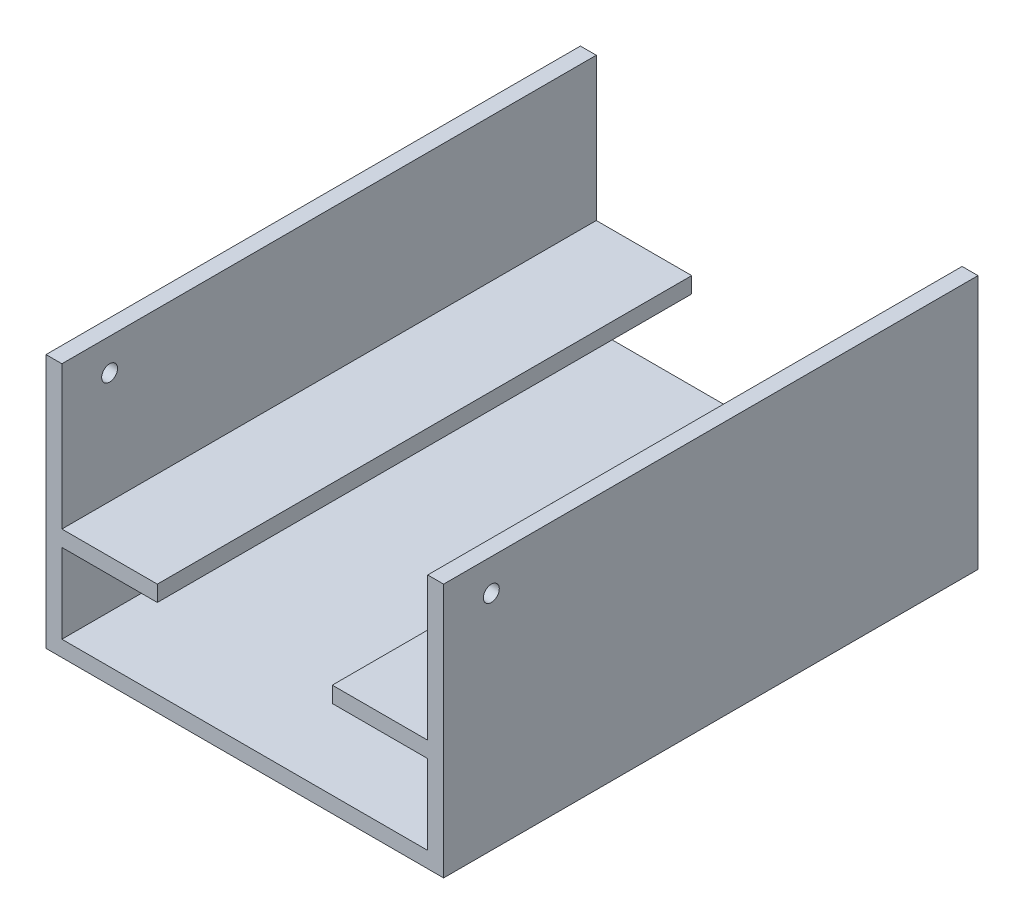
from build123d import *

# Parameters (mm, degrees)
CROQUIS1_W                 = 125
CROQUIS1_H                 = 168
SALIENTE_EXTRUIR1_DEPTH    = 5
CROQUIS2_W                 = 5
CROQUIS2_H                 = 168
SALIENTE_EXTRUIR2_DEPTH    = 75
CROQUIS3_W                 = 5
CROQUIS3_H                 = 168
SALIENTE_EXTRUIR3_DEPTH    = 75
CROQUIS4_W                 = 168
CROQUIS4_H                 = 5
SALIENTE_EXTRUIR4_DEPTH    = 30
CROQUIS5_W                 = 168
CROQUIS5_H                 = 5
SALIENTE_EXTRUIR5_DEPTH    = 30
CROQUIS6_R                 = 2.5
CORTAR_EXTRUIR1_DEPTH      = 31
CORTAR_EXTRUIR1_DEPTH_BACK = 135


with BuildPart() as part:
    # Croquis1 → Saliente-Extruir1 (new body)
    with BuildSketch(Plane(origin=(0, 0, 0), x_dir=(1, 0, 0), z_dir=(0, 1, 0))):
        with Locations((62.5, 84)):
            Rectangle(CROQUIS1_W, CROQUIS1_H)
    extrude(amount=SALIENTE_EXTRUIR1_DEPTH)

    # Croquis2 → Saliente-Extruir2 (add)
    with BuildSketch(Plane(origin=(0, 5, 0), x_dir=(1, 0, 0), z_dir=(0, 1, 0))):
        with Locations((2.5, 84)):
            Rectangle(CROQUIS2_W, CROQUIS2_H)
    extrude(amount=SALIENTE_EXTRUIR2_DEPTH)

    # Croquis3 → Saliente-Extruir3 (add)
    with BuildSketch(Plane(origin=(0, 5, 0), x_dir=(1, 0, 0), z_dir=(0, 1, 0))):
        with Locations((122.5, 84)):
            Rectangle(CROQUIS3_W, CROQUIS3_H)
    extrude(amount=SALIENTE_EXTRUIR3_DEPTH)

    # Croquis4 → Saliente-Extruir4 (add)
    with BuildSketch(Plane(origin=(5, 0, 0), x_dir=(0, 0, -1), z_dir=(1, 0, 0))):
        with Locations((84, 32.5)):
            Rectangle(CROQUIS4_W, CROQUIS4_H)
    extrude(amount=SALIENTE_EXTRUIR4_DEPTH)

    # Croquis5 → Saliente-Extruir5 (add)
    with BuildSketch(Plane.ZY.offset(-120)):
        with Locations((-84, 32.5)):
            Rectangle(CROQUIS5_W, CROQUIS5_H)
    extrude(amount=SALIENTE_EXTRUIR5_DEPTH)

    # Croquis6 → Cortar-Extruir1 (cut, two sides)
    with BuildSketch(Plane.ZY) as cortar_extruir1_sk:
        with Locations((-15, 70)):
            Circle(CROQUIS6_R)
    extrude(amount=CORTAR_EXTRUIR1_DEPTH, mode=Mode.SUBTRACT)
    extrude(cortar_extruir1_sk.sketch, amount=-CORTAR_EXTRUIR1_DEPTH_BACK, mode=Mode.SUBTRACT)


solid = part.part
